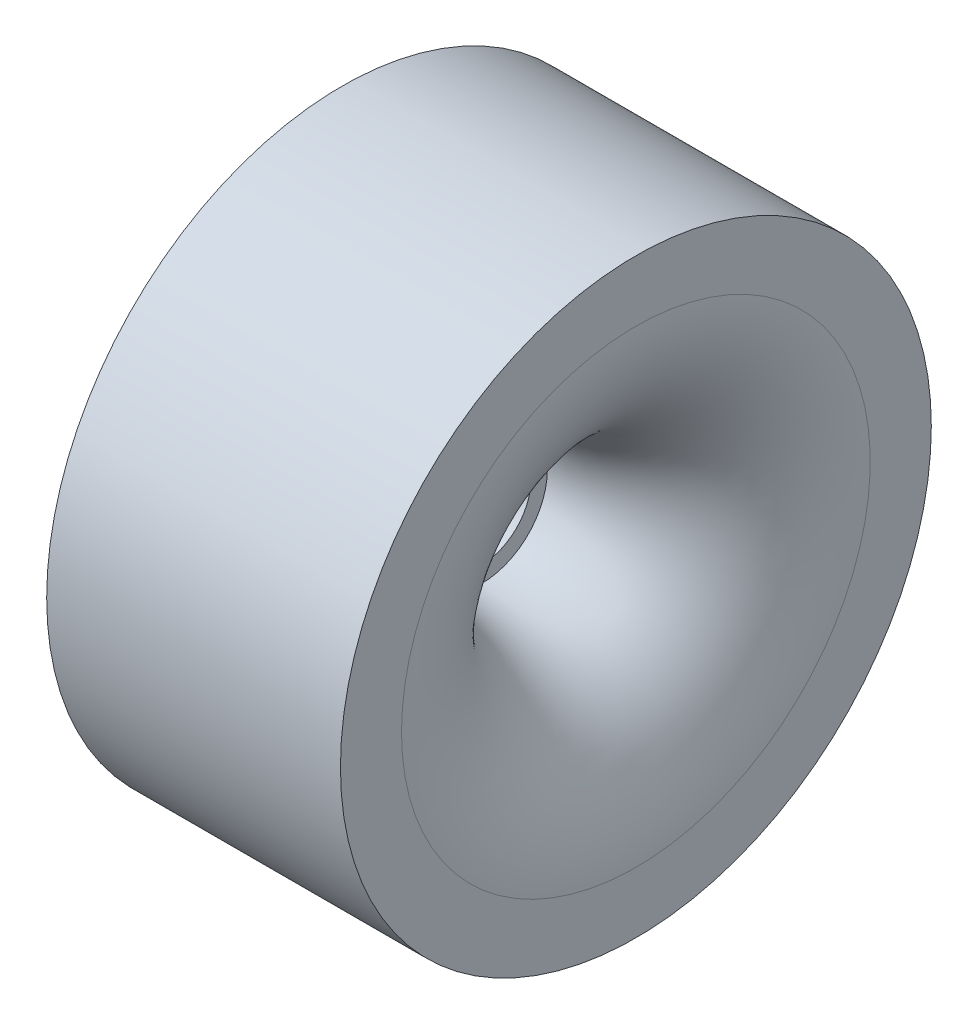
from build123d import *

# Parameters (mm, degrees)
SKETCH2_R           = 10.500659562
SKETCH2_R_2         = 5
BOSS_EXTRUDE2_DEPTH = 13.182787508


with BuildPart() as part:
    # Sketch1 → Revolve1 (revolve)
    with BuildSketch(Plane.XY):
        with BuildLine():
            Line((10.667721535, 30.050515382), (15.667721535, 30.050515382))
            Line((15.667721535, 30.050515382), (15.667721535, 23.838456429))
            ThreePointArc((15.667721535, 23.838456429), (11.249332557, 12.133123747), (0, 6.656857557))
            Line((0, 6.656857557), (0, 10.500659562))
            ThreePointArc((0, 10.500659562), (9.779386002, 14.025882573), (13.211146798, 23.838456429))
            Line((13.211146798, 23.838456429), (-14.211146798, 23.838456429))
            Line((-14.211146798, 23.838456429), (-14.211146798, 30.050515382))
            Line((-14.211146798, 30.050515382), (-9.211146798, 30.050515382))
            Line((-9.211146798, 30.050515382), (10.667721535, 30.050515382))
        make_face()
    revolve(axis=Axis((0, 0, 0), (1, 0, 0)))

    # Sketch2 → Boss-Extrude2 (add)
    with BuildSketch(Plane.ZY):
        Circle(SKETCH2_R)
        Circle(SKETCH2_R_2, mode=Mode.SUBTRACT)
    extrude(amount=BOSS_EXTRUDE2_DEPTH)


solid = part.part
